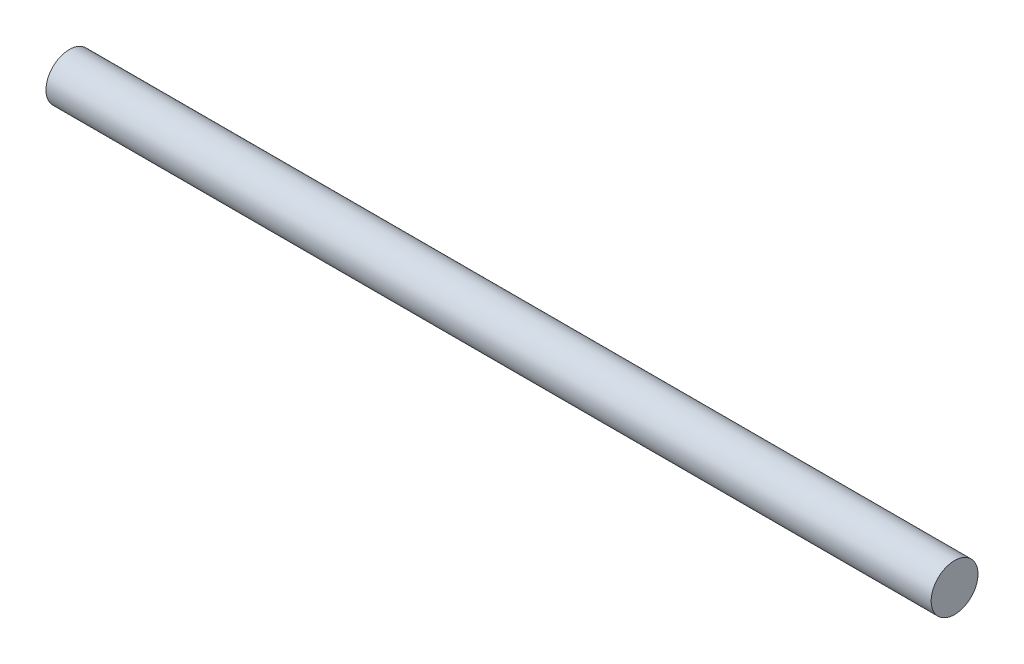
from build123d import *

# Parameters (mm, degrees)
SKETCH1_R           = 1.5875
BOSS_EXTRUDE1_DEPTH = 30


with BuildPart() as part:
    # Sketch1 → Boss-Extrude1 (new body, symmetric)
    with BuildSketch(Plane(origin=(0, 0, 0), x_dir=(0, 0, -1), z_dir=(1, 0, 0))):
        Circle(SKETCH1_R)
    extrude(amount=BOSS_EXTRUDE1_DEPTH, both=True)


solid = part.part
